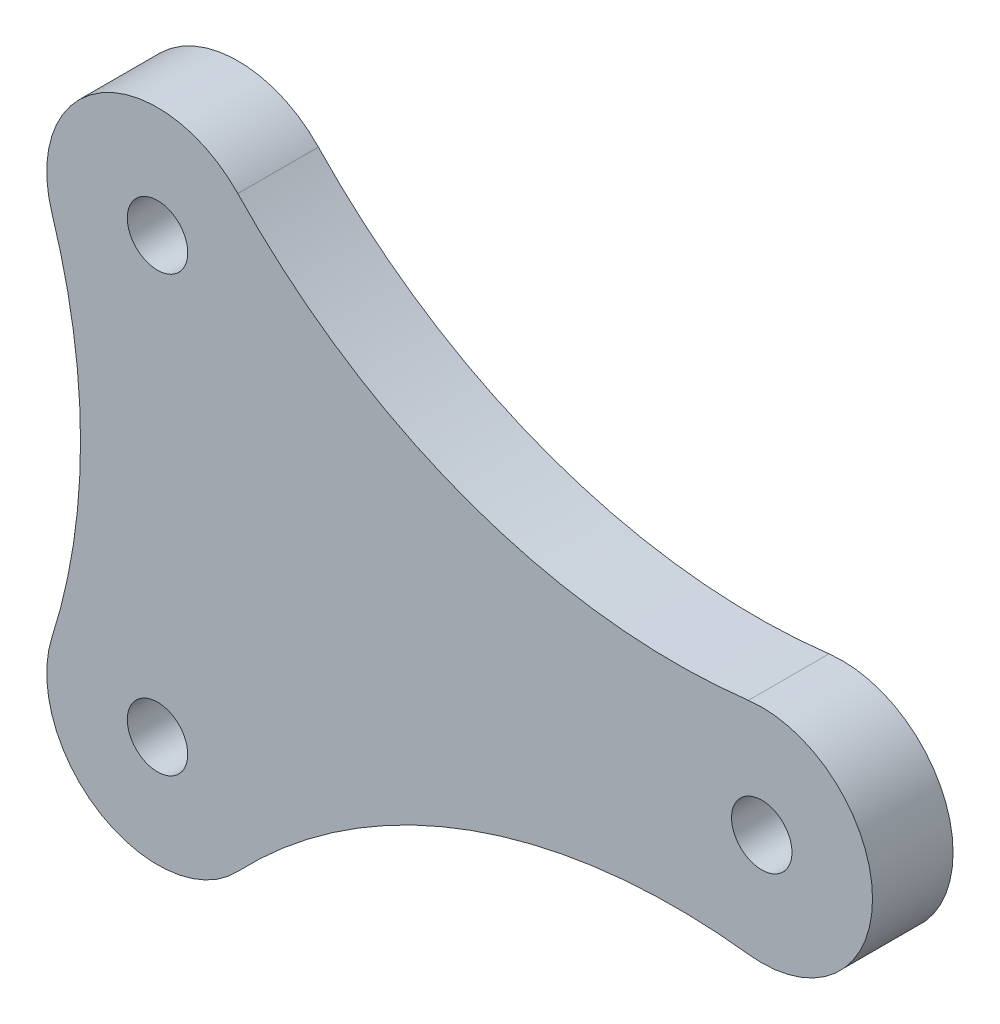
from build123d import *

# Parameters (mm, degrees)
SKETCH1_R           = 1.5
BOSS_EXTRUDE1_DEPTH = 4


with BuildPart() as part:
    # Sketch1 → Boss-Extrude1 (new body)
    with BuildSketch(Plane.XY):
        with BuildLine():
            ThreePointArc((3.986498359, 25.359172843), (-2.801068394, 26.303288059), (-5.24004212, 19.899084507))
            ThreePointArc((-5.24004212, 19.899084507), (-3.822090045, 10.785), (-5.24004212, 1.670915493))
            ThreePointArc((-5.24004212, 1.670915493), (-2.801068394, -4.733288059), (3.986498359, -3.789172843))
            ThreePointArc((3.986498359, -3.789172843), (15.581947878, 3.773729824), (29.338611035, 5.324911664))
            ThreePointArc((29.338611035, 5.324911664), (35.5, 10.785), (29.338611035, 16.245088336))
            ThreePointArc((29.338611035, 16.245088336), (15.581947878, 17.796270176), (3.986498359, 25.359172843))
        make_face()
        with Locations((0, 21.57)):
            Circle(SKETCH1_R, mode=Mode.SUBTRACT)
        with Locations((30, 10.785)):
            Circle(SKETCH1_R, mode=Mode.SUBTRACT)
        Circle(SKETCH1_R, mode=Mode.SUBTRACT)
    extrude(amount=BOSS_EXTRUDE1_DEPTH)


solid = part.part
